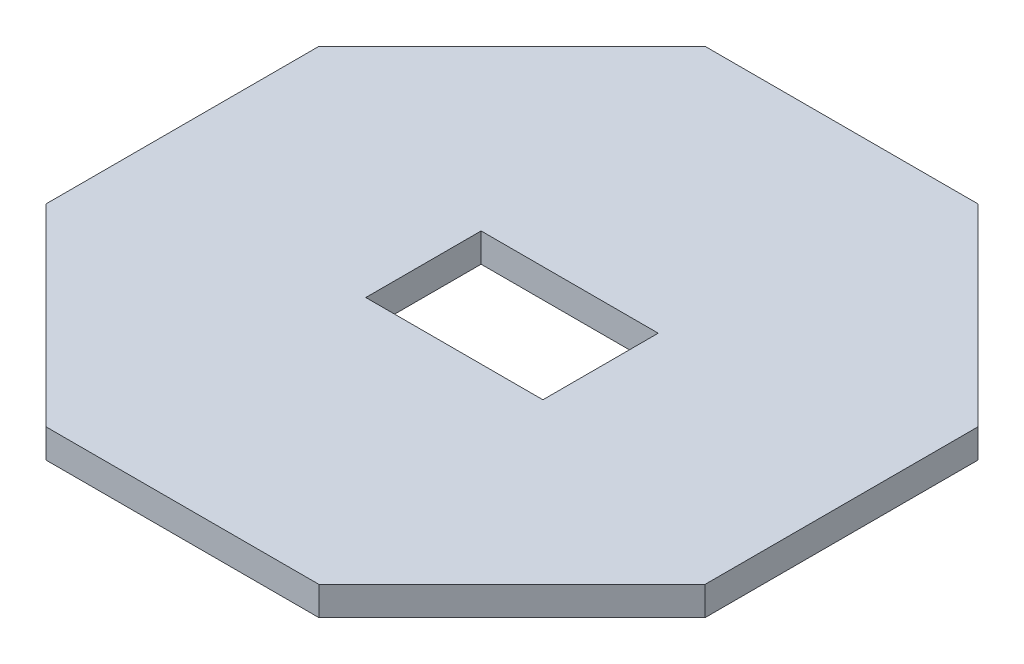
from build123d import *

# Parameters (mm, degrees)
SKETCH1_W           = 21.5
SKETCH1_H           = 14
BOSS_EXTRUDE1_DEPTH = 3.5


with BuildPart() as part:
    # Sketch1 → Boss-Extrude1 (new body)
    with BuildSketch(Plane(origin=(0, 0, 0), x_dir=(1, 0, 0), z_dir=(0, 1, 0))):
        Polygon((40, 16.568542495), (16.568542495, 40), (-16.568542495, 40), (-40, 16.568542495), (-40, -16.568542495), (-16.568542495, -40), (16.568542495, -40), (40, -16.568542495), align=None)
        Rectangle(SKETCH1_W, SKETCH1_H, mode=Mode.SUBTRACT)
    extrude(amount=BOSS_EXTRUDE1_DEPTH)


solid = part.part
